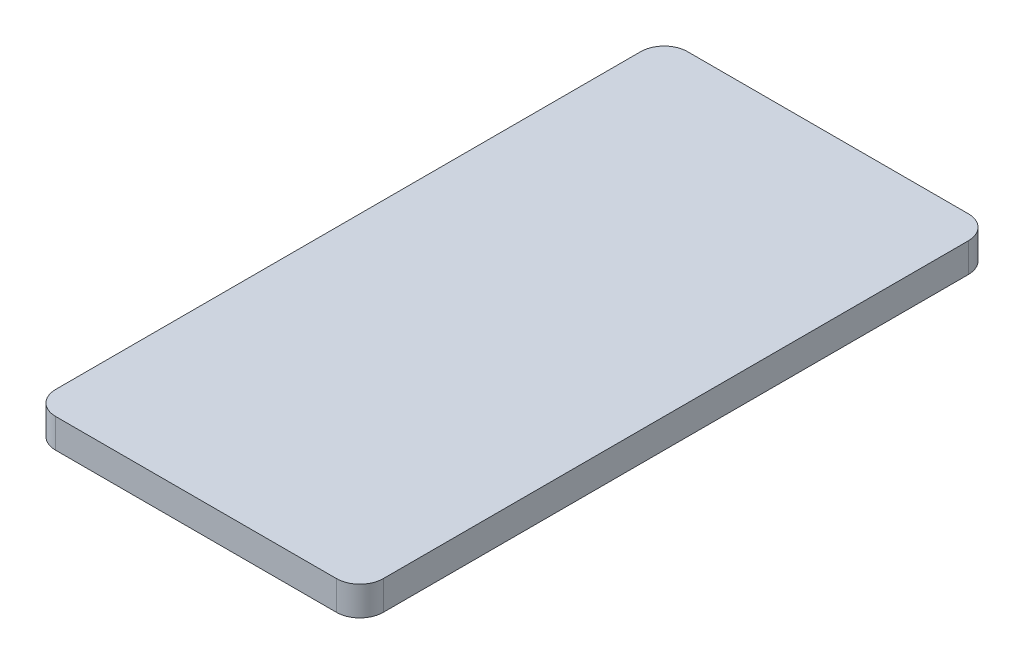
from build123d import *

# Parameters (mm, degrees)
BOSS_EXTRUDE1_DEPTH = 3.175


with BuildPart() as part:
    # Sketch1 → Boss-Extrude1 (new body)
    with BuildSketch(Plane(origin=(0, 0, 0), x_dir=(1, 0, 0), z_dir=(0, 1, 0))):
        with BuildLine():
            Line((-15.24, -34.29), (15.24, -34.29))
            ThreePointArc((15.24, -34.29), (17.036051224, -33.546051224), (17.78, -31.75))
            Line((17.78, -31.75), (17.78, 31.75))
            ThreePointArc((17.78, 31.75), (17.036051224, 33.546051224), (15.24, 34.29))
            Line((15.24, 34.29), (-15.24, 34.29))
            ThreePointArc((-15.24, 34.29), (-17.036051224, 33.546051224), (-17.78, 31.75))
            Line((-17.78, 31.75), (-17.78, -31.75))
            ThreePointArc((-17.78, -31.75), (-17.036051224, -33.546051224), (-15.24, -34.29))
        make_face()
    extrude(amount=BOSS_EXTRUDE1_DEPTH)


solid = part.part
